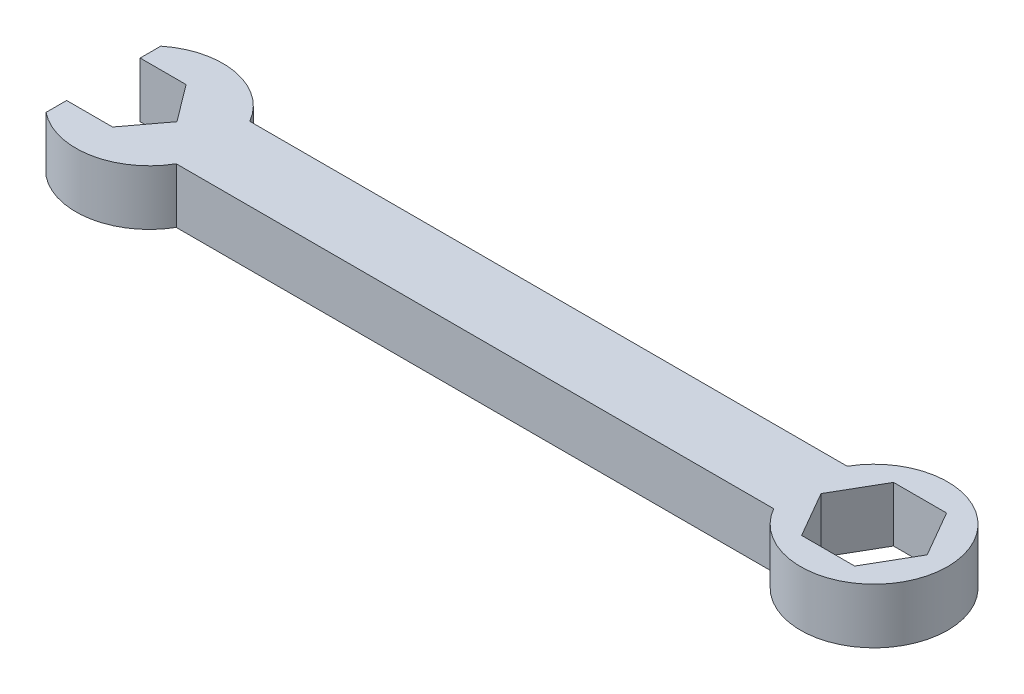
from build123d import *

# Parameters (mm, degrees)
BOSS_EXTRUDE1_DEPTH = 7.62


with BuildPart() as part:
    # Sketch2 → Boss-Extrude1 (new body)
    with BuildSketch(Plane(origin=(0, 0, 0), x_dir=(1, 0, 0), z_dir=(0, 1, 0))):
        with BuildLine():
            Line((-41.275, 5.08), (41.275, 5.08))
            ThreePointArc((41.275, 5.08), (60.233818102, 0), (41.275, -5.08))
            Line((41.275, -5.08), (-41.275, -5.08))
            ThreePointArc((-41.275, -5.08), (-48.194606038, -9.984696391), (-56.423818102, -7.931147458))
            Line((-56.423818102, -7.931147458), (-56.423818102, -5.08))
            Line((-56.423818102, -5.08), (-50.073818102, -5.08))
            Line((-50.073818102, -5.08), (-46.263818102, 0))
            Line((-46.263818102, 0), (-50.073818102, 5.08))
            Line((-50.073818102, 5.08), (-56.423818102, 5.08))
            Line((-56.423818102, 5.08), (-56.423818102, 7.931147458))
            ThreePointArc((-56.423818102, 7.931147458), (-48.194606038, 9.984696391), (-41.275, 5.08))
        make_face()
        Polygon((53.739992312, -6.35), (57.406166521, 0), (53.739992312, 6.35), (46.407643893, 6.35), (42.741469684, 0), (46.407643893, -6.35), align=None, mode=Mode.SUBTRACT)
    extrude(amount=BOSS_EXTRUDE1_DEPTH)


solid = part.part
